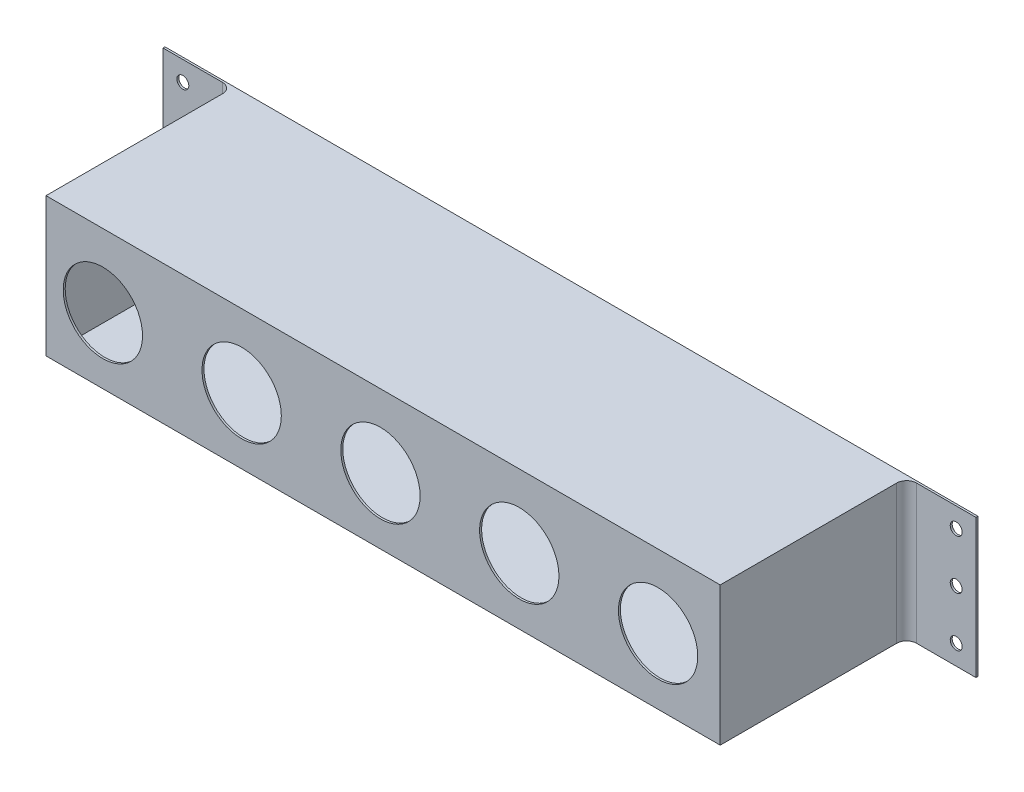
from build123d import *

# Parameters (mm, degrees)
SKETCH_1_W          = 410
SKETCH_1_H          = 70
EXTRUDE_1_DEPTH     = 95
SKETCH_2_W          = 35
SKETCH_2_H          = 94
CUT_EXTRUDE_1_DEPTH = 95
SHELL_1_T           = -1
FILLET_2_R          = 5
SKETCH_3_R          = 2.9999999999999947
SKETCH_3_R_2        = 2.999999999999994
SKETCH_3_R_3        = 3.000000000000047
CUT_EXTRUDE_2_DEPTH = 229.22357459298556
SKETCH_4_R          = 20.000000000000004
SKETCH_4_R_2        = 20
SKETCH_4_R_3        = 19.999999999999986
CUT_EXTRUDE_3_DEPTH = 229.63726730347355


with BuildPart() as part:
    # 草图1 → 凸台-拉伸1 (new body)
    with BuildSketch(Plane.XY):
        Rectangle(SKETCH_1_W, SKETCH_1_H)
    extrude(amount=EXTRUDE_1_DEPTH)

    # 草图2 → 切除-拉伸1 (cut)
    with BuildSketch(Plane(origin=(0, 34.99999999999999, 0), x_dir=(1, 0, 0), z_dir=(0, 1, 0))):
        with Locations((187.49999999999997, -48)):
            Rectangle(SKETCH_2_W, SKETCH_2_H)
        Polygon((-204.99999999999997, -1.0000000000001206), (-204.99999999999991, -95.00000000000011), (-169.99999999999994, -95.00000000000011), (-169.99999999999997, -1.0000000000001001), align=None)
    extrude(amount=-CUT_EXTRUDE_1_DEPTH, mode=Mode.SUBTRACT)

    # 抽壳1
    shell_1_openings = [part.faces().sort_by_distance(p)[0] for p in [
        (0, 0, 0),
    ]]
    offset(amount=SHELL_1_T, openings=shell_1_openings, kind=Kind.INTERSECTION)

    # 圆角2
    fillet_2_edges = [part.edges().sort_by_distance(p)[0] for p in [
        (169.99999999999997, -7.11e-15, 1.0000000000000009),
        (-169.99999999999997, -7.11e-15, 1.0000000000001001),
    ]]
    fillet(fillet_2_edges, radius=FILLET_2_R)

    # 草图3 → 切除-拉伸2 (cut, through all)
    with BuildSketch(Plane.XY.offset(1.000000000000001)):
        with Locations((194.99999999999994, 24.999999999999993)):
            Circle(SKETCH_3_R)
        with Locations(Location((194.99999999999994, -25.000000000000007, 0), (0, 0, 180))):
            Circle(SKETCH_3_R)
        with Locations((194.99999999999994, -6.94e-15)):
            Circle(SKETCH_3_R_2)
        with Locations(Location((-194.9999999999999, -1.5959e-13, 0), (0, 0, 180))):
            Circle(SKETCH_3_R_3)
        with Locations(Location((-194.99999999999994, 24.999999999999837, 0), (0, 0, 180))):
            Circle(SKETCH_3_R)
        with Locations((-194.9999999999999, -25.00000000000016)):
            Circle(SKETCH_3_R)
    extrude(amount=-CUT_EXTRUDE_2_DEPTH, mode=Mode.SUBTRACT)

    # 草图4 → 切除-拉伸3 (cut, through all)
    with BuildSketch(Plane.XY.offset(95)):
        with Locations((-141.32999999999993, -1.8400000000000152)):
            Circle(SKETCH_4_R)
        with Locations((-71.32999999999993, -1.8400000000000152)):
            Circle(SKETCH_4_R)
        with Locations((-1.3299999999999146, -1.8400000000000152)):
            Circle(SKETCH_4_R_2)
        with Locations((68.67000000000009, -1.8400000000000152)):
            Circle(SKETCH_4_R)
        with Locations((138.6700000000001, -1.8400000000000152)):
            Circle(SKETCH_4_R_3)
    extrude(amount=-CUT_EXTRUDE_3_DEPTH, mode=Mode.SUBTRACT)


solid = part.part
